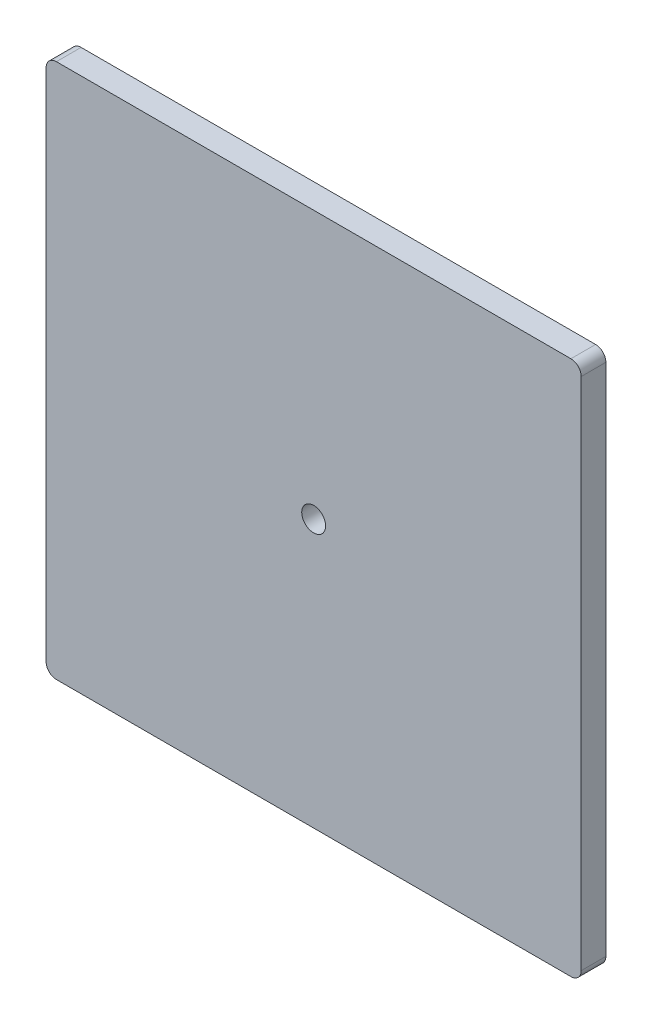
from build123d import *

# Parameters (mm, degrees)
BOSS_EXTRUDE1_DEPTH = 12
SKETCH2_R           = 5.795
CUT_EXTRUDE1_DEPTH  = 10


with BuildPart() as part:
    # Sketch1 → Boss-Extrude1 (new body)
    with BuildSketch(Plane.XY):
        with BuildLine():
            Line((-125, 130), (125, 130))
            ThreePointArc((125, 130), (128.535533906, 128.535533906), (130, 125))
            Line((130, 125), (130, -125))
            ThreePointArc((130, -125), (128.535533906, -128.535533906), (125, -130))
            Line((125, -130), (-125, -130))
            ThreePointArc((-125, -130), (-128.535533906, -128.535533906), (-130, -125))
            Line((-130, -125), (-130, 125))
            ThreePointArc((-130, 125), (-128.535533906, 128.535533906), (-125, 130))
        make_face()
    extrude(amount=BOSS_EXTRUDE1_DEPTH)

    # Sketch2 → Cut-Extrude1 (cut)
    with BuildSketch(Plane.XY.offset(12)):
        Circle(SKETCH2_R)
    extrude(amount=-CUT_EXTRUDE1_DEPTH, mode=Mode.SUBTRACT)


solid = part.part
